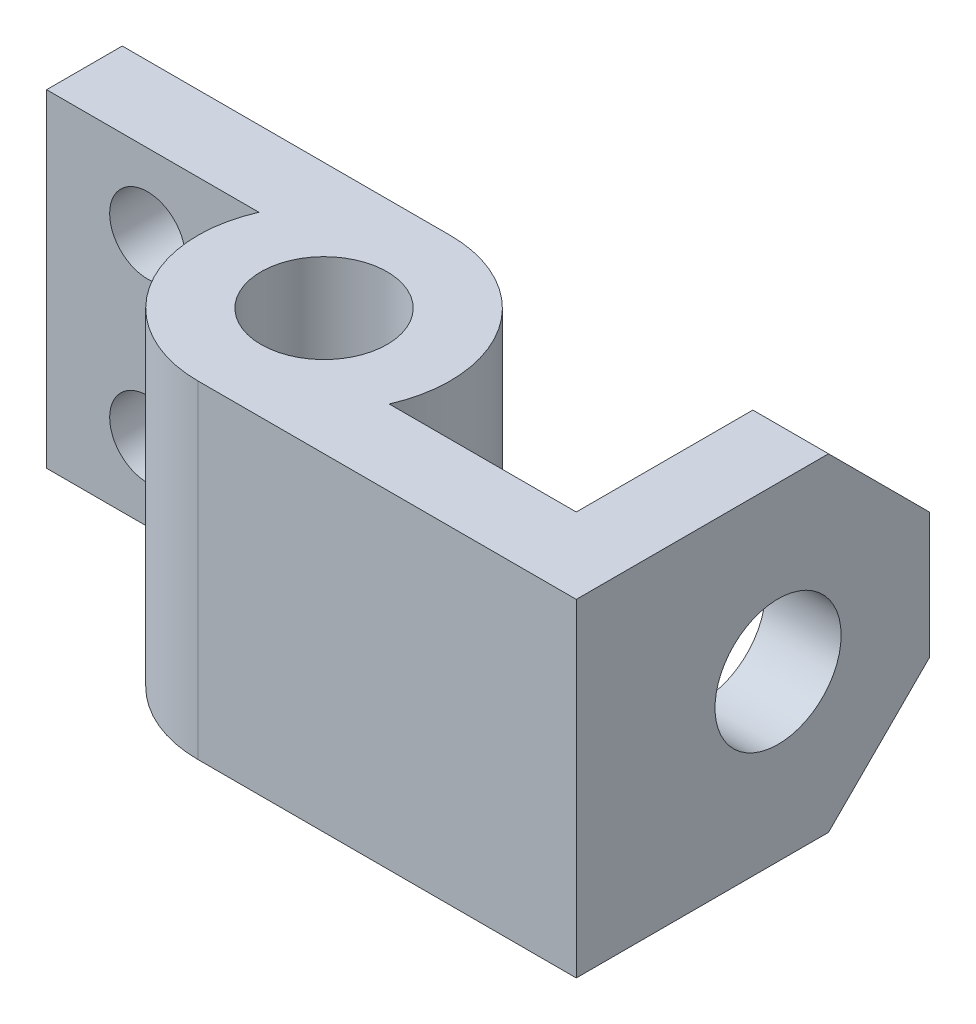
from build123d import *

# Parameters (mm, degrees)
SKETCH1_R           = 15.875
BOSS_EXTRUDE1_DEPTH = 82.55
SKETCH2_R           = 15.875
CUT_EXTRUDE1_DEPTH  = 41.402
SKETCH3_R           = 9.525
CUT_EXTRUDE2_DEPTH  = 41.402
CHAMFER1_SIZE       = 25.4
CHAMFER2_SIZE       = 25.4


with BuildPart() as part:
    # Sketch1 → Boss-Extrude1 (new body)
    with BuildSketch(Plane(origin=(0, 0, 0), x_dir=(1, 0, 0), z_dir=(0, 1, 0))):
        with BuildLine():
            Line((0, 31.75), (-82.55, 31.75))
            Line((-82.55, 31.75), (-82.55, 12.7))
            Line((-82.55, 12.7), (-29.099355663, 12.7))
            ThreePointArc((-29.099355663, 12.7), (-26.563955842, -17.390191201), (0, -31.75))
            Line((0, -31.75), (95.25, -31.75))
            Line((95.25, -31.75), (95.25, 57.15))
            Line((95.25, 57.15), (76.2, 57.15))
            Line((76.2, 57.15), (76.2, -12.7))
            Line((76.2, -12.7), (29.099355663, -12.7))
            ThreePointArc((29.099355663, -12.7), (26.563955842, 17.390191201), (0, 31.75))
        make_face()
        Circle(SKETCH1_R, mode=Mode.SUBTRACT)
    extrude(amount=BOSS_EXTRUDE1_DEPTH)

    # Sketch2 → Cut-Extrude1 (cut)
    with BuildSketch(Plane(origin=(95.25, 0, 0), x_dir=(0, 0, -1), z_dir=(1, 0, 0))):
        with Locations((19.05, 41.402)):
            Circle(SKETCH2_R)
    extrude(amount=-CUT_EXTRUDE1_DEPTH, mode=Mode.SUBTRACT)

    # Sketch3 → Cut-Extrude2 (cut)
    with BuildSketch(Plane(origin=(0, 0, -31.75), x_dir=(-1, 0, 0), z_dir=(0, 0, -1))):
        with Locations((57.15, 63.5)):
            Circle(SKETCH3_R)
        with Locations((57.15, 19.05)):
            Circle(SKETCH3_R)
    extrude(amount=-CUT_EXTRUDE2_DEPTH, mode=Mode.SUBTRACT)

    # Chamfer1
    chamfer1_edges = [part.edges().sort_by_distance(p)[0] for p in [
        (85.725, 82.55, -57.15),
    ]]
    chamfer(chamfer1_edges, length=CHAMFER1_SIZE)

    # Chamfer2
    chamfer2_edges = [part.edges().sort_by_distance(p)[0] for p in [
        (85.725, 0, -57.15),
    ]]
    chamfer(chamfer2_edges, length=CHAMFER2_SIZE)


solid = part.part
